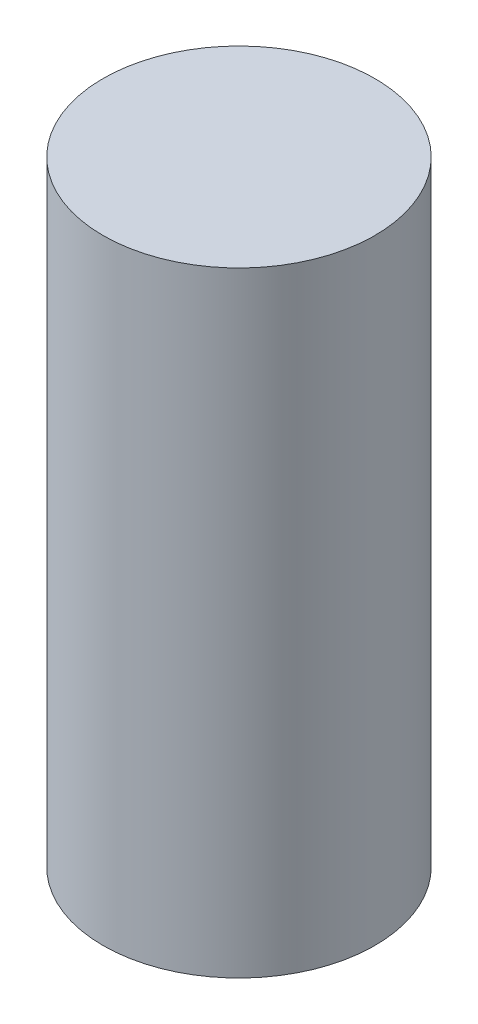
from build123d import *

# Parameters (mm, degrees)
SKETCH1_R           = 3.975
BOSS_EXTRUDE1_DEPTH = 17.98


with BuildPart() as part:
    # Sketch1 → Boss-Extrude1 (new body)
    with BuildSketch(Plane(origin=(0, 0, 0), x_dir=(1, 0, 0), z_dir=(0, 1, 0))):
        with Locations(Location((0, 0, 0), (0, 0, 270))):  # turned: the seam where the file's is
            Circle(SKETCH1_R)
    extrude(amount=BOSS_EXTRUDE1_DEPTH)


solid = part.part
